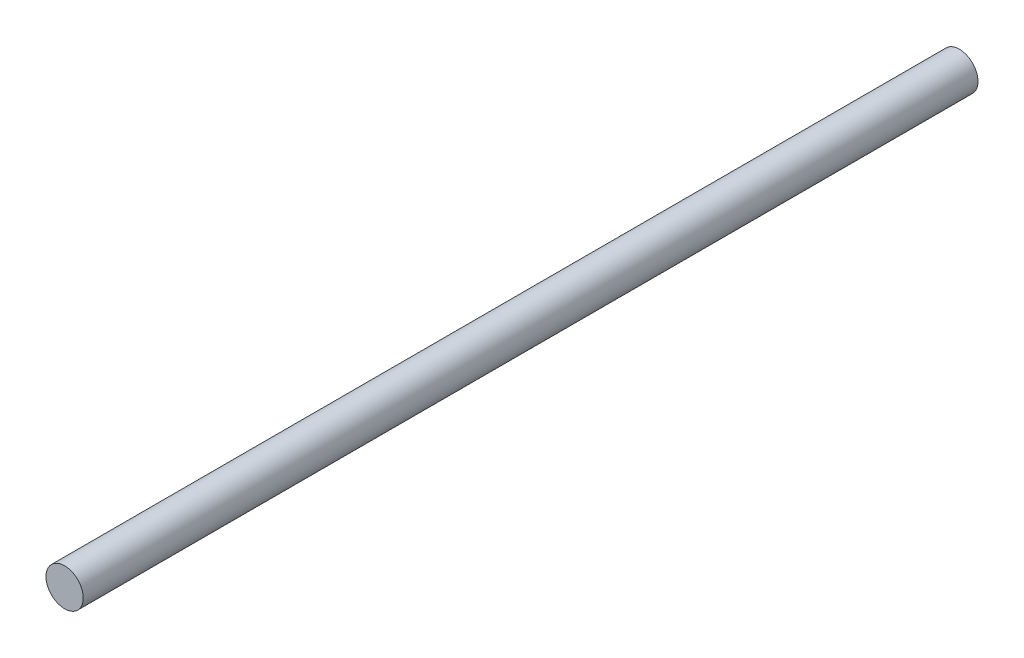
from build123d import *

# Parameters (mm, degrees)
SKETCH1_R           = 6.35
BOSS_EXTRUDE1_DEPTH = 152.4


with BuildPart() as part:
    # Sketch1 → Boss-Extrude1 (new body, symmetric)
    with BuildSketch(Plane.XY):
        Circle(SKETCH1_R)
    extrude(amount=BOSS_EXTRUDE1_DEPTH, both=True)


solid = part.part
